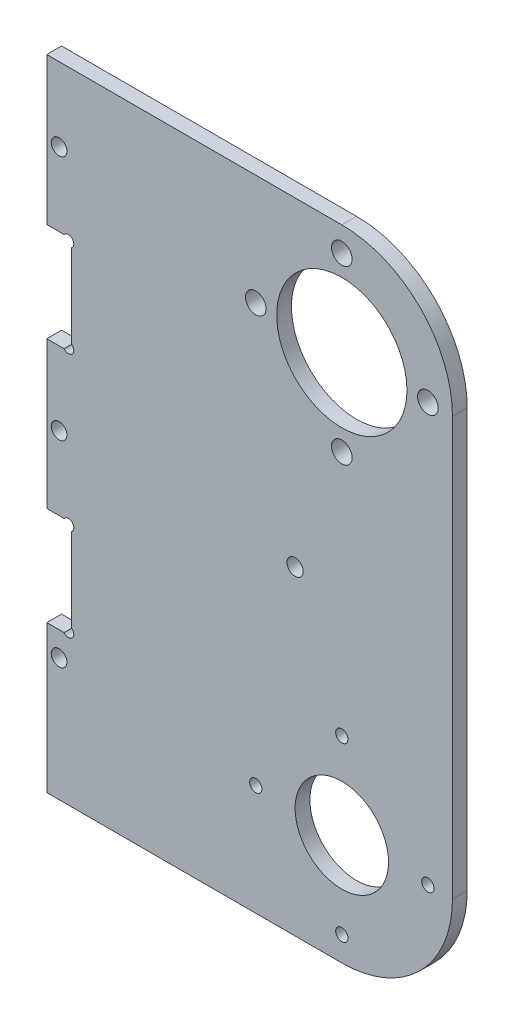
from build123d import *

# Parameters (mm, degrees)
SKETCH_2_R          = 9.5
SKETCH_2_R_2        = 1.25
SKETCH_2_R_3        = 13.25
SKETCH_2_R_4        = 2.1
EXTRUDE_1_DEPTH     = 3
SKETCH_4_R          = 1.6
CUT_EXTRUDE_1_DEPTH = 10
SKETCH_5_R          = 1.65
CUT_EXTRUDE_2_DEPTH = 10


with BuildPart() as part:
    # ｽｹｯﾁ2 → ﾎﾞｽ - 押し出し1 (new body)
    with BuildSketch(Plane.XY):
        with BuildLine():
            Line((-60, -22.5), (-40, -22.5))
            Line((-40, -22.5), (0, -22.5))
            ThreePointArc((0, -22.5), (15.909902577, -15.909902577), (22.5, 0))
            Line((22.5, 0), (22.5, 85))
            ThreePointArc((22.5, 85), (15.909902577, 100.909902577), (0, 107.5))
            Line((0, 107.5), (-40, 107.5))
            Line((-40, 107.5), (-60, 107.5))
            Line((-60, 107.5), (-60, -22.5))
        make_face()
        Circle(SKETCH_2_R, mode=Mode.SUBTRACT)
        with Locations((0, 17.5)):
            Circle(SKETCH_2_R_2, mode=Mode.SUBTRACT)
        with Locations((17.5, 0)):
            Circle(SKETCH_2_R_2, mode=Mode.SUBTRACT)
        with Locations((0, -17.5)):
            Circle(SKETCH_2_R_2, mode=Mode.SUBTRACT)
        with Locations((-17.5, 0)):
            Circle(SKETCH_2_R_2, mode=Mode.SUBTRACT)
        with Locations((0, 85)):
            Circle(SKETCH_2_R_3, mode=Mode.SUBTRACT)
        with Locations((0, 67.5)):
            Circle(SKETCH_2_R_4, mode=Mode.SUBTRACT)
        with Locations((-17.5, 85)):
            Circle(SKETCH_2_R_4, mode=Mode.SUBTRACT)
        with Locations((0, 102.5)):
            Circle(SKETCH_2_R_4, mode=Mode.SUBTRACT)
        with Locations((17.5, 85)):
            Circle(SKETCH_2_R_4, mode=Mode.SUBTRACT)
    extrude(amount=EXTRUDE_1_DEPTH)

    # ｽｹｯﾁ4 → ｶｯﾄ - 押し出し1 (cut)
    with BuildSketch(Plane.XY.offset(3)):
        with BuildLine():
            Line((-56.49, 77.55), (-60, 77.55))
            Line((-60, 77.55), (-60, 57.45))
            Line((-60, 57.45), (-56.49, 57.45))
            ThreePointArc((-56.49, 57.45), (-54.832182541, 57.332182541), (-54.95, 58.99))
            Line((-54.95, 58.99), (-54.95, 76.01))
            ThreePointArc((-54.95, 76.01), (-54.832182541, 77.667817459), (-56.49, 77.55))
        make_face()
        with BuildLine():
            Line((-56.49, 27.55), (-60, 27.55))
            Line((-60, 27.55), (-60, 7.45))
            Line((-60, 7.45), (-56.49, 7.45))
            ThreePointArc((-56.49, 7.45), (-54.832182541, 7.332182541), (-54.95, 8.99))
            Line((-54.95, 8.99), (-54.95, 26.01))
            ThreePointArc((-54.95, 26.01), (-54.832182541, 27.667817459), (-56.49, 27.55))
        make_face()
        with Locations((-57.5, 2.5)):
            Circle(SKETCH_4_R)
        with Locations((-57.5, 42.5)):
            Circle(SKETCH_4_R)
        with Locations((-57.5, 92.5)):
            Circle(SKETCH_4_R)
    extrude(amount=-CUT_EXTRUDE_1_DEPTH, mode=Mode.SUBTRACT)

    # ｽｹｯﾁ5 → ｶｯﾄ - 押し出し2 (cut)
    with BuildSketch(Plane.XY.offset(3)):
        with Locations((-9.5, 42.5)):
            Circle(SKETCH_5_R)
    extrude(amount=-CUT_EXTRUDE_2_DEPTH, mode=Mode.SUBTRACT)


solid = part.part
